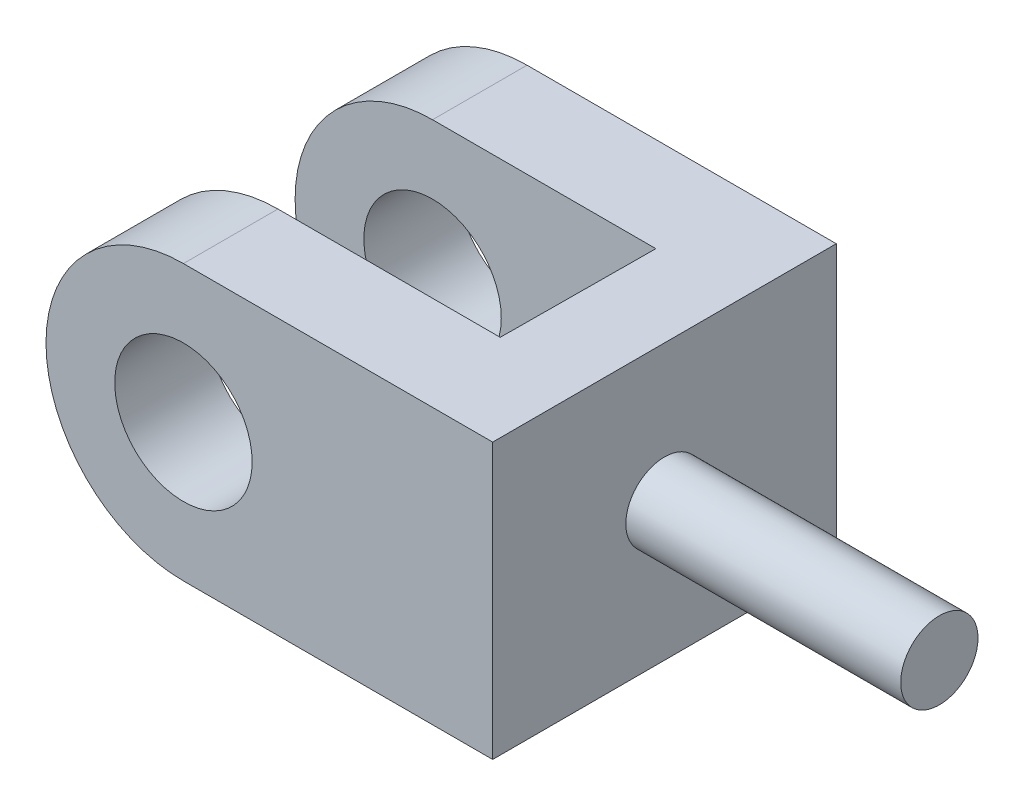
from build123d import *

# Parameters (mm, degrees)
SKETCH2_R           = 8
BOSS_EXTRUDE1_DEPTH = 40
CUT_EXTRUDE1_DEPTH  = 40
SKETCH4_R           = 4.5
BOSS_EXTRUDE2_DEPTH = 32


with BuildPart() as part:
    # Sketch2 → Boss-Extrude1 (new body)
    with BuildSketch(Plane.XY):
        with BuildLine():
            Line((0, 0), (36, 0))
            Line((36, 0), (36, 32))
            Line((36, 32), (0, 32))
            ThreePointArc((0, 32), (-16, 16), (0, 0))
        make_face()
        with Locations((0, 16)):
            Circle(SKETCH2_R, mode=Mode.SUBTRACT)
    extrude(amount=BOSS_EXTRUDE1_DEPTH)

    # Sketch3 → Cut-Extrude1 (cut)
    with BuildSketch(Plane(origin=(0, 32, 0), x_dir=(1, 0, 0), z_dir=(0, 1, 0))):
        Polygon((26, -11), (0, -11), (0, -29), (25.876198368, -29), align=None)
        Polygon((0, -11), (-16, -11), (-16.123801632, -29), (0, -29), align=None)
    extrude(amount=-CUT_EXTRUDE1_DEPTH, mode=Mode.SUBTRACT)

    # Sketch4 → Boss-Extrude2 (add)
    with BuildSketch(Plane(origin=(36, 0, 0), x_dir=(0, 0, -1), z_dir=(1, 0, 0))):
        with Locations((-20, 16)):
            Circle(SKETCH4_R)
    extrude(amount=BOSS_EXTRUDE2_DEPTH)


solid = part.part
